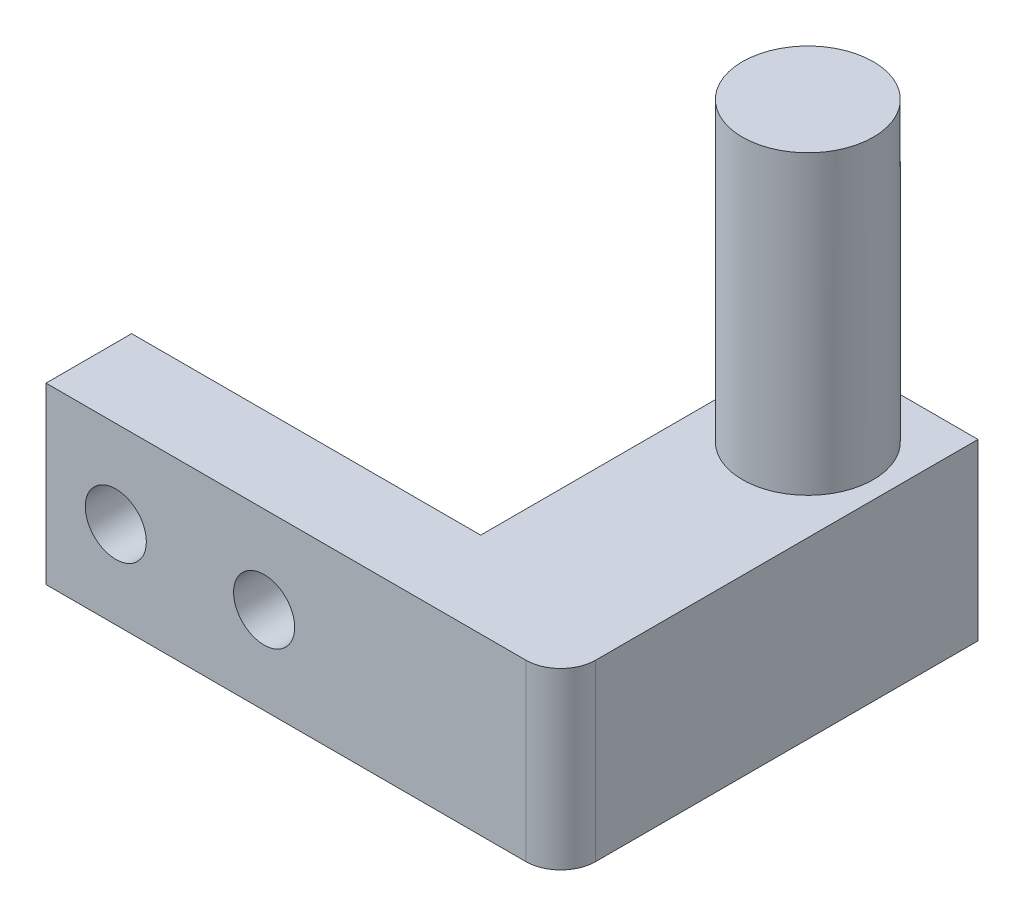
from build123d import *

# Parameters (mm, degrees)
SKETCH1_W           = 12.5
SKETCH1_H           = 10
BOSS_EXTRUDE1_DEPTH = 10
SKETCH2_W           = 10
SKETCH2_H           = 10
BOSS_EXTRUDE2_DEPTH = 5
SKETCH3_R           = 3.75
BOSS_EXTRUDE3_DEPTH = 17
SKETCH4_W           = 4
SKETCH4_H           = 10
CUT_EXTRUDE1_DEPTH  = 11
SKETCH5_W           = 9.5
SKETCH5_H           = 10
BOSS_EXTRUDE4_DEPTH = 12.5
SKETCH6_W           = 5
SKETCH6_H           = 10
BOSS_EXTRUDE5_DEPTH = 30
SKETCH7_R           = 1.75
CUT_EXTRUDE2_DEPTH  = 23.5
SKETCH8_W           = 30
SKETCH8_H           = 5
CUT_EXTRUDE4_DEPTH  = 10
SKETCH10_W          = 9.5
SKETCH10_H          = 10
CUT_EXTRUDE6_DEPTH  = 3.49
SKETCH11_W          = 9.5
SKETCH11_H          = 10
BOSS_EXTRUDE6_DEPTH = 3.9
SKETCH12_W          = 4
SKETCH12_H          = 10
BOSS_EXTRUDE7_DEPTH = 20
SKETCH13_W          = 20
SKETCH13_H          = 0.09
CUT_EXTRUDE7_DEPTH  = 28
SKETCH14_R          = 1.75
CUT_EXTRUDE8_DEPTH  = 23.91
SKETCH15_W          = 20
SKETCH15_H          = 3.91
CUT_EXTRUDE9_DEPTH  = 11
SKETCH16_W          = 3.91
SKETCH16_H          = 10
BOSS_EXTRUDE8_DEPTH = 20
SKETCH17_R          = 1.75
CUT_EXTRUDE10_DEPTH = 20
SKETCH18_W          = 29.5
SKETCH18_H          = 10
SKETCH18_R          = 1.75
BOSS_EXTRUDE9_DEPTH = 1
FILLET1_R           = 2


with BuildPart() as part:
    # Sketch1 → Boss-Extrude1 (new body)
    with BuildSketch(Plane.XY):
        with Locations((6.25, 5)):
            Rectangle(SKETCH1_W, SKETCH1_H)
    extrude(amount=BOSS_EXTRUDE1_DEPTH)

    # Sketch2 → Boss-Extrude2 (add)
    with BuildSketch(Plane.ZY):
        with Locations((5, 5)):
            Rectangle(SKETCH2_W, SKETCH2_H)
    extrude(amount=BOSS_EXTRUDE2_DEPTH)

    # Sketch3 → Boss-Extrude3 (add)
    with BuildSketch(Plane(origin=(0, 10, 0), x_dir=(1, 0, 0), z_dir=(0, 1, 0))):
        with Locations((3.75, -5)):
            Circle(SKETCH3_R)
    extrude(amount=BOSS_EXTRUDE3_DEPTH)

    # Sketch4 → Cut-Extrude1 (cut, through all)
    with BuildSketch(Plane(origin=(0, 10, 0), x_dir=(1, 0, 0), z_dir=(0, 1, 0))):
        with Locations((10.5, -5)):
            Rectangle(SKETCH4_W, SKETCH4_H)
        with Locations((-3, -5)):
            Rectangle(SKETCH4_W, SKETCH4_H)
    extrude(amount=-CUT_EXTRUDE1_DEPTH, mode=Mode.SUBTRACT)

    # Sketch5 → Boss-Extrude4 (add)
    with BuildSketch(Plane.XY.offset(10)):
        with Locations((3.75, 5)):
            Rectangle(SKETCH5_W, SKETCH5_H)
    extrude(amount=BOSS_EXTRUDE4_DEPTH)

    # Sketch6 → Boss-Extrude5 (add)
    with BuildSketch(Plane(origin=(8.5, 0, 0), x_dir=(0, 0, -1), z_dir=(1, 0, 0))):
        with Locations((-20, 5)):
            Rectangle(SKETCH6_W, SKETCH6_H)
    extrude(amount=BOSS_EXTRUDE5_DEPTH)

    # Sketch7 → Cut-Extrude2 (cut, through all)
    with BuildSketch(Plane.XY.offset(22.5)):
        with Locations((22.5, 5)):
            Circle(SKETCH7_R)
        with Locations((33.5, 5)):
            Circle(SKETCH7_R)
    extrude(amount=-CUT_EXTRUDE2_DEPTH, mode=Mode.SUBTRACT)

    # Sketch8 → Cut-Extrude4 (cut)
    with BuildSketch(Plane(origin=(0, 10, 0), x_dir=(1, 0, 0), z_dir=(0, 1, 0))):
        with Locations((23.5, -20)):
            Rectangle(SKETCH8_W, SKETCH8_H)
    extrude(amount=-CUT_EXTRUDE4_DEPTH, mode=Mode.SUBTRACT)

    # Sketch10 → Cut-Extrude6 (cut)
    with BuildSketch(Plane.XY.offset(22.5)):
        with Locations((3.75, 5)):
            Rectangle(SKETCH10_W, SKETCH10_H)
    extrude(amount=-CUT_EXTRUDE6_DEPTH, mode=Mode.SUBTRACT)

    # Sketch11 → Boss-Extrude6 (add)
    with BuildSketch(Plane.XY.offset(19.01)):
        with Locations((3.75, 5)):
            Rectangle(SKETCH11_W, SKETCH11_H)
    extrude(amount=BOSS_EXTRUDE6_DEPTH)

    # Sketch12 → Boss-Extrude7 (add)
    with BuildSketch(Plane(origin=(8.5, 0, 0), x_dir=(0, 0, -1), z_dir=(1, 0, 0))):
        with Locations((-20.91, 5)):
            Rectangle(SKETCH12_W, SKETCH12_H)
    extrude(amount=BOSS_EXTRUDE7_DEPTH)

    # Sketch13 → Cut-Extrude7 (cut, through all)
    with BuildSketch(Plane(origin=(0, 0, 0), x_dir=(-1, 0, 0), z_dir=(0, -1, 0))):
        with Locations((-18.5, -18.955)):
            Rectangle(SKETCH13_W, SKETCH13_H)
    extrude(amount=-CUT_EXTRUDE7_DEPTH, mode=Mode.SUBTRACT)

    # Sketch14 → Cut-Extrude8 (cut, through all)
    with BuildSketch(Plane.XY.offset(22.91)):
        with Locations((16, 5)):
            Circle(SKETCH14_R)
        with Locations((24.5, 5)):
            Circle(SKETCH14_R)
    extrude(amount=-CUT_EXTRUDE8_DEPTH, mode=Mode.SUBTRACT)

    # Sketch15 → Cut-Extrude9 (cut, through all)
    with BuildSketch(Plane(origin=(0, 10, 0), x_dir=(1, 0, 0), z_dir=(0, 1, 0))):
        with Locations((18.5, -20.955)):
            Rectangle(SKETCH15_W, SKETCH15_H)
    extrude(amount=-CUT_EXTRUDE9_DEPTH, mode=Mode.SUBTRACT)

    # Sketch16 → Boss-Extrude8 (add)
    with BuildSketch(Plane.ZY.offset(1)):
        with Locations((20.955, 5)):
            Rectangle(SKETCH16_W, SKETCH16_H)
    extrude(amount=BOSS_EXTRUDE8_DEPTH)

    # Sketch17 → Cut-Extrude10 (cut)
    with BuildSketch(Plane.XY.offset(22.91)):
        with Locations((-17, 5)):
            Circle(SKETCH17_R)
        with Locations((-8.5, 5)):
            Circle(SKETCH17_R)
    extrude(amount=-CUT_EXTRUDE10_DEPTH, mode=Mode.SUBTRACT)

    # Sketch18 → Boss-Extrude9 (add)
    with BuildSketch(Plane.XY.offset(22.91)):
        with Locations((-6.25, 5)):
            Rectangle(SKETCH18_W, SKETCH18_H)
        with Locations((-17, 5)):
            Circle(SKETCH18_R, mode=Mode.SUBTRACT)
        with Locations((-8.5, 5)):
            Circle(SKETCH18_R, mode=Mode.SUBTRACT)
    extrude(amount=BOSS_EXTRUDE9_DEPTH)

    # Fillet1
    fillet1_edges = [part.edges().sort_by_distance(p)[0] for p in [
        (8.5, 5, 23.91),
    ]]
    fillet(fillet1_edges, radius=FILLET1_R)


solid = part.part
